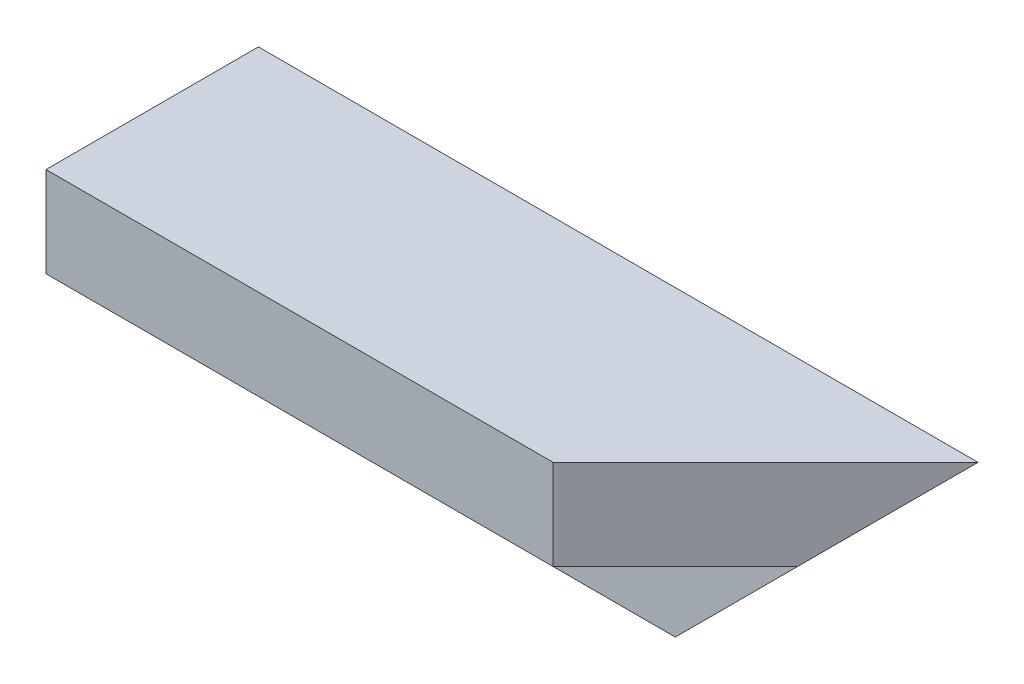
from build123d import *

# Parameters (mm, degrees)
BOSS_EXTRU_1_START      = 83.500046
BOSS_EXTRU_1_DEPTH      = 135.5
ENL_V_MAT_EXTRU_1_DEPTH = 41
ENL_V_MAT_EXTRU_2_DEPTH = 41


with BuildPart() as part:
    # Esquisse1 → Boss.-Extru.1 (new body)
    with BuildSketch(Plane(origin=(0, 0, 0), x_dir=(0, 0, -1), z_dir=(1, 0, 0)).offset(BOSS_EXTRU_1_START)):
        Polygon((0, 0), (-40, 0), (-40, -17), (-17, -17), (-17, -40), (0, -40), align=None)
    extrude(amount=BOSS_EXTRU_1_DEPTH)

    # Esquisse2 → Enlèv. mat.-Extru.1 (cut, through all)
    with BuildSketch(Plane(origin=(0, 0, 0), x_dir=(1, 0, 0), z_dir=(0, 1, 0))):
        Polygon((219.000046471, 0), (179.000046471, -40), (219.000046471, -40), align=None)
    extrude(amount=-ENL_V_MAT_EXTRU_1_DEPTH, mode=Mode.SUBTRACT)

    # Esquisse3 → Enlèv. mat.-Extru.2 (cut, through all)
    with BuildSketch(Plane(origin=(0, 0, 0), x_dir=(-1, 0, 0), z_dir=(0, 0, -1))):
        Polygon((-219.000046471, 0), (-179.000046471, -40), (-219.000046471, -40), align=None)
    extrude(amount=-ENL_V_MAT_EXTRU_2_DEPTH, mode=Mode.SUBTRACT)


solid = part.part
